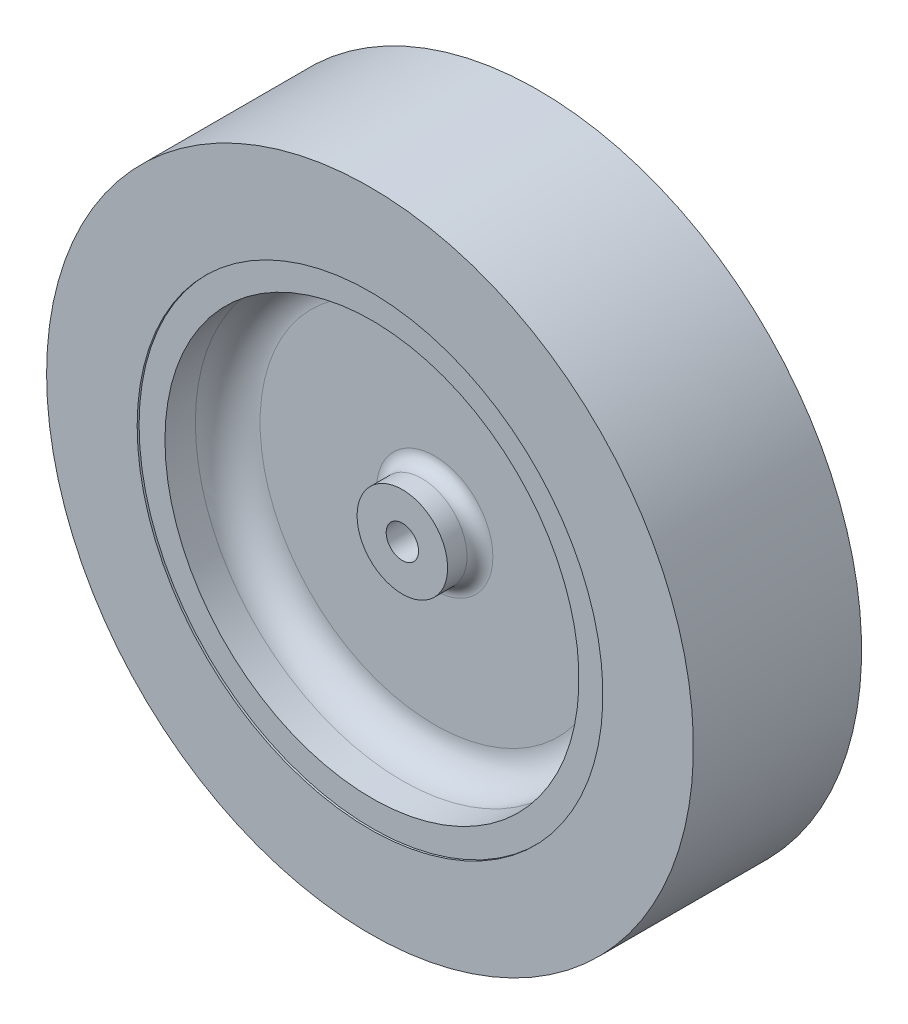
from build123d import *

# Parameters (mm, degrees)
FILLET1_R = 5
FILLET2_R = 2
FILLET3_R = 5
FILLET4_R = 2


with BuildPart() as part:
    # Sketch2 → Revolve2 (revolve)
    with BuildSketch(Plane(origin=(0, 0, 0), x_dir=(0, 0, -1), z_dir=(1, 0, 0))):
        Polygon((-8, 2.5), (8, 2.5), (8, 7), (3, 7), (3, 32), (12.7, 32), (12.7, 36), (13, 36), (13, 50), (-13, 50), (-13, 36), (-12.7, 36), (-12.7, 32), (-3, 32), (-3, 7), (-8, 7), align=None)
    revolve(axis=Axis((0, 0, -5.520153215), (0, 0, 1)))

    # Fillet1
    fillet1_edges = [part.edges().sort_by_distance(p)[0] for p in [
        (0, -32, -3),
    ]]
    fillet(fillet1_edges, radius=FILLET1_R)

    # Fillet2
    fillet2_edges = [part.edges().sort_by_distance(p)[0] for p in [
        (0, -7, -3),
    ]]
    fillet(fillet2_edges, radius=FILLET2_R)

    # Fillet3
    fillet3_edges = [part.edges().sort_by_distance(p)[0] for p in [
        (0, -32, 3),
    ]]
    fillet(fillet3_edges, radius=FILLET3_R)

    # Fillet4
    fillet4_edges = [part.edges().sort_by_distance(p)[0] for p in [
        (0, -7, 3),
    ]]
    fillet(fillet4_edges, radius=FILLET4_R)


solid = part.part
